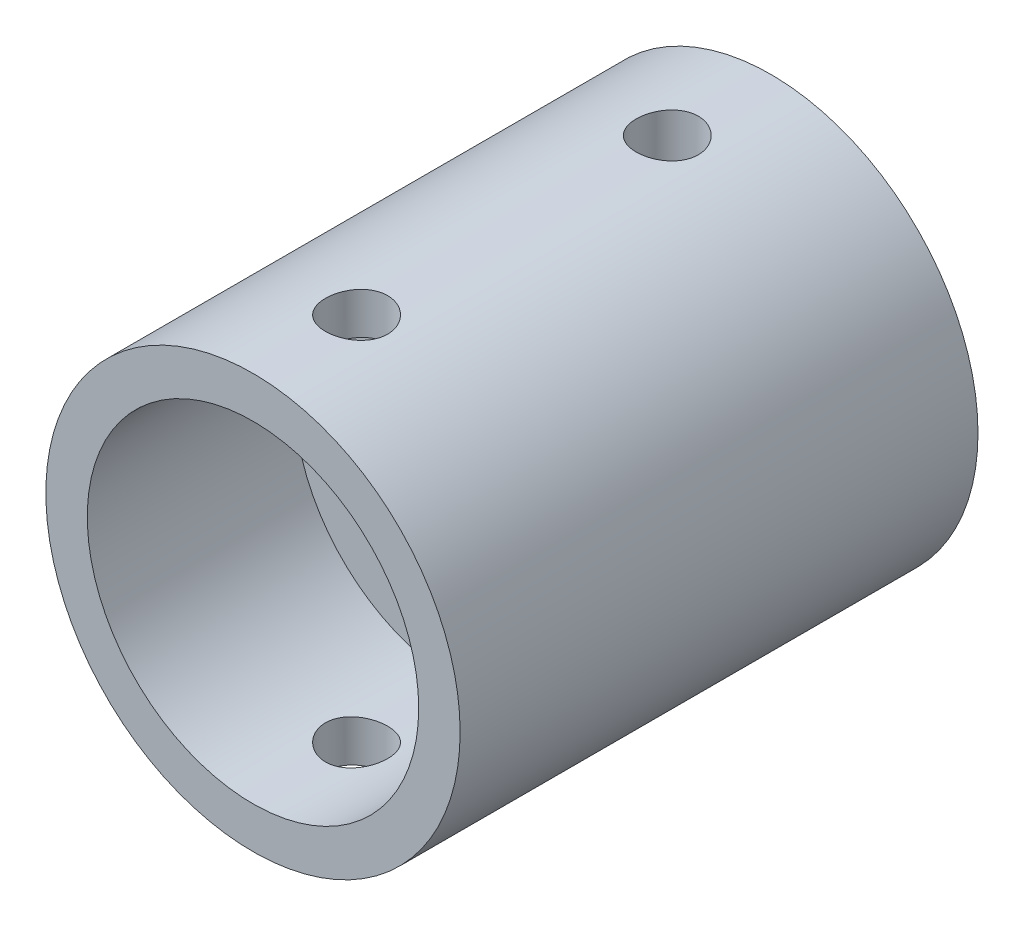
from build123d import *

# Parameters (mm, degrees)
ESQUISSE1_R                  = 20
ESQUISSE1_R_2                = 10.25
BOSS_EXTRU_1_DEPTH           = 50
ESQUISSE2_R                  = 16
ENL_V_MAT_EXTRU_1_DEPTH      = 20
ESQUISSE3_R                  = 3
ENL_V_MAT_EXTRU_2_DEPTH      = 21
ENL_V_MAT_EXTRU_2_DEPTH_BACK = 21


with BuildPart() as part:
    # Esquisse1 → Boss.-Extru.1 (new body)
    with BuildSketch(Plane.XY):
        Circle(ESQUISSE1_R)
        Circle(ESQUISSE1_R_2, mode=Mode.SUBTRACT)
    extrude(amount=BOSS_EXTRU_1_DEPTH)

    # Esquisse2 → Enlèv. mat.-Extru.1 (cut)
    with BuildSketch(Plane.XY.offset(50)):
        Circle(ESQUISSE2_R)
    extrude(amount=-ENL_V_MAT_EXTRU_1_DEPTH, mode=Mode.SUBTRACT)

    # Esquisse3 → Enlèv. mat.-Extru.2 (cut, two sides)
    with BuildSketch(Plane(origin=(0, 0, 0), x_dir=(1, 0, 0), z_dir=(0, 1, 0))) as enl_v_mat_extru_2_sk:
        with Locations(Location((0, -10, 0), (0, 0, 270))):  # turned: the seam where the file's is
            Circle(ESQUISSE3_R)
        with Locations(Location((0, -40, 0), (0, 0, 270))):  # turned: the seam where the file's is
            Circle(ESQUISSE3_R)
    extrude(amount=ENL_V_MAT_EXTRU_2_DEPTH, mode=Mode.SUBTRACT)
    extrude(enl_v_mat_extru_2_sk.sketch, amount=-ENL_V_MAT_EXTRU_2_DEPTH_BACK, mode=Mode.SUBTRACT)


solid = part.part
